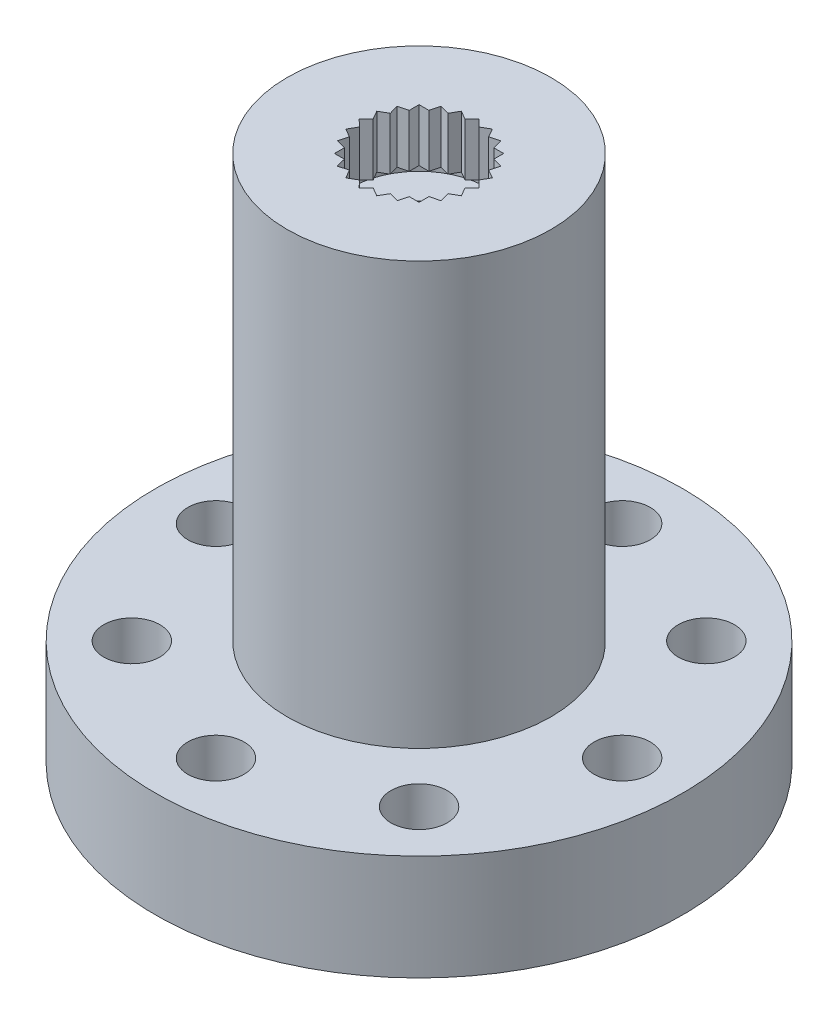
from build123d import *

# Parameters (mm, degrees)
SKETCH1_W                  = 12.69619
SKETCH1_H                  = 5.08
SKETCH2_R                  = 6.34619
BOSS_EXTRUDE1_DEPTH        = 20.32
SKETCH3_R                  = 3.26136
CUT_EXTRUDE1_DEPTH         = 0.508
CUT_EXTRUDE2_REACH         = 27.4
SKETCH5_R                  = 3.81
CUT_EXTRUDE3_DEPTH         = 21.082
SKETCH6_R                  = 1.5
CUT_EXTRUDE4_DEPTH         = 5.318
M2_5_CLEARANCE_HOLE1_D     = 2.7051
M2_5_CLEARANCE_HOLE1_DEPTH = 5.08


with BuildPart() as part:
    # Sketch1 → Revolve1 (revolve)
    with BuildSketch(Plane.XY):
        with Locations((6.348095, 2.54)):
            Rectangle(SKETCH1_W, SKETCH1_H)
    revolve(axis=Axis((0, 5.08, 0), (0, -1, 0)))

    # Sketch2 → Boss-Extrude1 (add)
    with BuildSketch(Plane(origin=(0, 5.08, 0), x_dir=(-1, 0, 0), z_dir=(0, 1, 0))):
        Circle(SKETCH2_R)
    extrude(amount=BOSS_EXTRUDE1_DEPTH)

    # Sketch3 → Cut-Extrude1 (cut)
    with BuildSketch(Plane.XZ.offset(-22.352)):
        Circle(SKETCH3_R)
    extrude(amount=-CUT_EXTRUDE1_DEPTH, mode=Mode.SUBTRACT)

    # Sketch4 → Cut-Extrude2 (cut, up to next)
    with BuildSketch(Plane(origin=(0, 25.4, 0), x_dir=(-1, 0, 0), z_dir=(0, 1, 0)), mode=Mode.PRIVATE) as cut_extrude2_sk1:
        Polygon((-2.494464932, -1.44018), (-2.035268659, -1.56171657), (-2.036722088, -2.036722088), (-1.56171657, -2.035268659), (-1.44018, -2.494464932), (-0.981736077, -2.370120553), (-0.745492025, -2.782214113), (-0.334851894, -2.543452647), (0, -2.88036), (0.334851894, -2.543452647), (0.745492025, -2.782214113), (0.981736077, -2.370120553), (1.44018, -2.494464932), (1.56171657, -2.035268659), (2.036722088, -2.036722088), (2.035268659, -1.56171657), (2.494464932, -1.44018), (2.370120553, -0.981736077), (2.782214113, -0.745492025), (2.543452647, -0.334851894), (2.88036, 0), (2.543452647, 0.334851894), (2.782214113, 0.745492025), (2.370120553, 0.981736077), (2.494464932, 1.44018), (2.035268659, 1.56171657), (2.036722088, 2.036722088), (1.56171657, 2.035268659), (1.44018, 2.494464932), (0.981736077, 2.370120553), (0.745492025, 2.782214113), (0.334851894, 2.543452647), (0, 2.88036), (-0.334851894, 2.543452647), (-0.745492025, 2.782214113), (-0.981736077, 2.370120553), (-1.44018, 2.494464932), (-1.56171657, 2.035268659), (-2.036722088, 2.036722088), (-2.035268659, 1.56171657), (-2.494464932, 1.44018), (-2.370120553, 0.981736077), (-2.782214113, 0.745492025), (-2.543452647, 0.334851894), (-2.88036, 0), (-2.543452647, -0.334851894), (-2.782214113, -0.745492025), (-2.370120553, -0.981736077), align=None)
    cut_extrude2_tool1 = extrude(cut_extrude2_sk1.sketch, amount=-CUT_EXTRUDE2_REACH, mode=Mode.PRIVATE) & part.part
    add(cut_extrude2_tool1.solids().sort_by_distance((0, 25.4, 0))[0], mode=Mode.SUBTRACT)

    # Sketch5 → Cut-Extrude3 (cut)
    with BuildSketch(Plane.XZ):
        Circle(SKETCH5_R)
    extrude(amount=-CUT_EXTRUDE3_DEPTH, mode=Mode.SUBTRACT)

    # Sketch6 → Cut-Extrude4 (cut, through all)
    with BuildSketch(Plane.XZ.offset(-21.082)):
        Circle(SKETCH6_R)
    extrude(amount=-CUT_EXTRUDE4_DEPTH, mode=Mode.SUBTRACT)

    # M2.5 Clearance Hole1
    with Locations(Plane(origin=(0, 5.08, 0), x_dir=(1, 0, 0), z_dir=(0, 1, 0))):
        with Locations((6.914797213, -6.914797213), (0, -9.779), (-6.914797213, -6.914797213), (-9.779, 0), (-6.914797213, 6.914797213), (0, 9.779), (6.914797213, 6.914797213), (9.779, 0)):
            Hole(M2_5_CLEARANCE_HOLE1_D / 2, depth=M2_5_CLEARANCE_HOLE1_DEPTH)


solid = part.part
